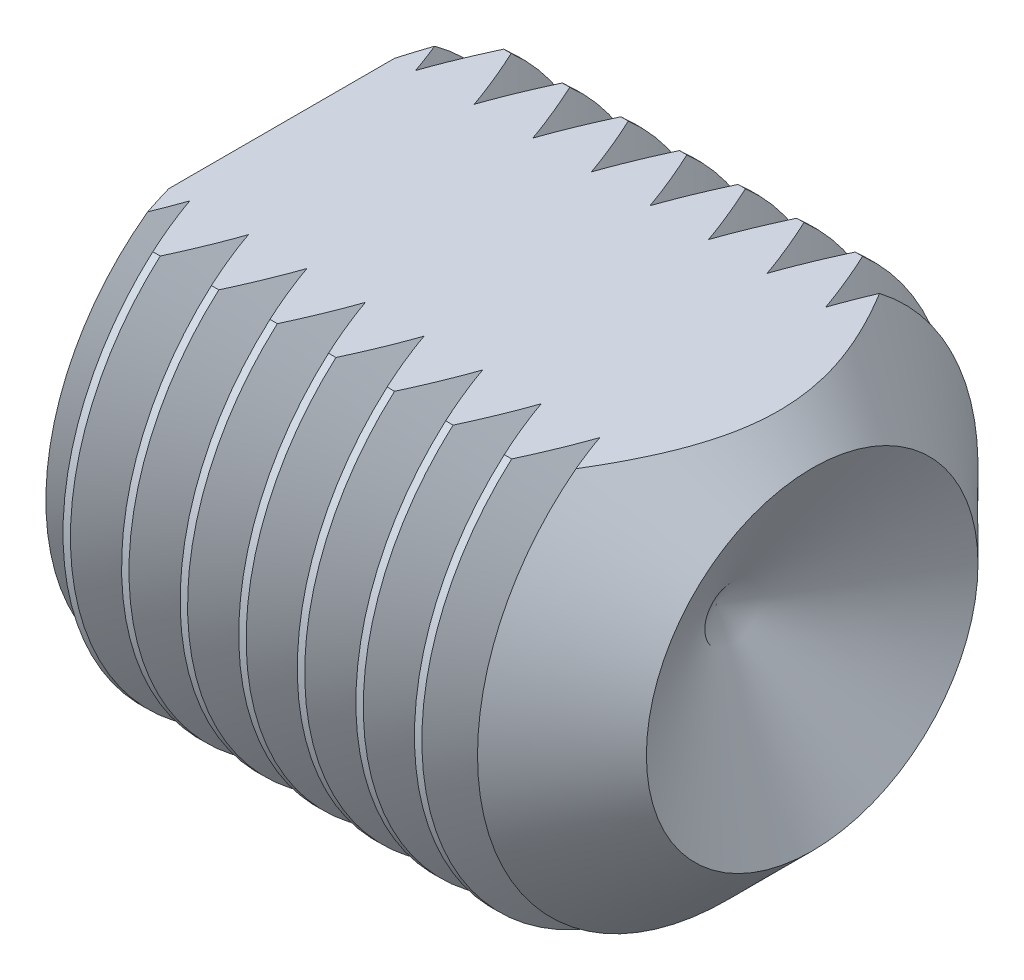
from build123d import *

# Parameters (mm, degrees)
HEX_2_DEPTH        = 6.4
THDSCHPAT_COUNT    = 8
THDSCHPAT_PITCH    = 1.766292682
SKETCH3_W          = 30.420600684
SKETCH3_H          = 33.851495499
CUT_EXTRUDE1_DEPTH = 2


with BuildPart() as part:
    # BodySke → BaseBody (revolve)
    with BuildSketch(Plane.XY):
        Polygon((0, 0), (0, 6.8985), (0.635951322, 8), (13, 8), (16, 5), (13.113248654, 0), align=None)
    revolve(axis=Axis((-12.7, 0, 0), (1, 0, 0)))

    # Sketch2 → Hex 2 (cut)
    with BuildSketch(Plane.ZY):
        Polygon((2.309401077, 4), (-2.309401077, 4), (-4.618802154, 0), (-2.309401077, -4), (2.309401077, -4), (4.618802154, 0), align=None)
    extrude(amount=-HEX_2_DEPTH, mode=Mode.SUBTRACT)

    # ThdSchSke → ThreadSchematic (revolve, cut)
    with BuildSketch(Plane.XY):
        Polygon((0.635951322, -6.8985), (-0.135327282, -8), (-0.135327282, -10), (1.407229925, -10), (1.407229925, -8), align=None)
    threadschematic = revolve(axis=Axis((-3.175, 0, 0), (1, 0, 0)), mode=Mode.SUBTRACT)

    # ThdSchPat: ThreadSchematic ×8
    with Locations(*[(i * THDSCHPAT_PITCH, 0, 0) for i in range(1, THDSCHPAT_COUNT)]):
        add(threadschematic, mode=Mode.SUBTRACT)

    # Sketch3 → Cut-Extrude1 (cut)
    with BuildSketch(Plane(origin=(0, 8, 0), x_dir=(-1, 0, 0), z_dir=(0, 1, 0))):
        with Locations((-7.768215545, -1.918808929)):
            Rectangle(SKETCH3_W, SKETCH3_H)
    extrude(amount=-CUT_EXTRUDE1_DEPTH, mode=Mode.SUBTRACT)


solid = part.part
